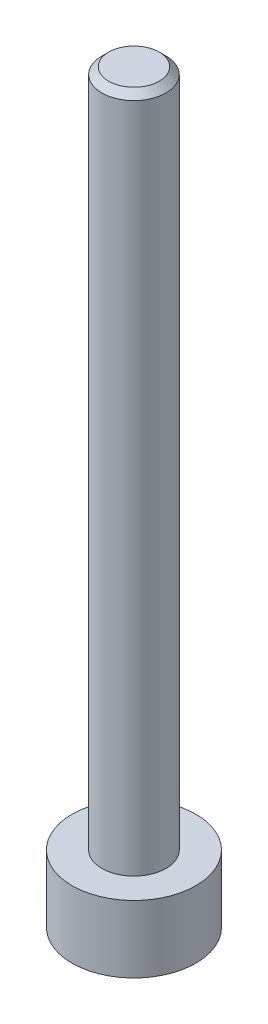
from build123d import *

# Parameters (mm, degrees)
SKETCH1_R           = 1.825
BOSS_EXTRUDE1_DEPTH = 1.98
SKETCH2_R           = 0.945
BOSS_EXTRUDE2_DEPTH = 20
CUT_EXTRUDE1_DEPTH  = 1
CHAMFER1_SIZE       = 0.2


with BuildPart() as part:
    # Sketch1 → Boss-Extrude1 (new body)
    with BuildSketch(Plane(origin=(0, 0, 0), x_dir=(1, 0, 0), z_dir=(0, 1, 0))):
        Circle(SKETCH1_R)
    extrude(amount=BOSS_EXTRUDE1_DEPTH)

    # Sketch2 → Boss-Extrude2 (add)
    with BuildSketch(Plane(origin=(0, 1.98, 0), x_dir=(1, 0, 0), z_dir=(0, 1, 0))):
        Circle(SKETCH2_R)
    extrude(amount=BOSS_EXTRUDE2_DEPTH)

    # Sketch3 → Cut-Extrude1 (cut)
    with BuildSketch(Plane.XZ):
        Polygon((0.458993464, -0.795), (0.917986928, 0), (0.458993464, 0.795), (-0.458993464, 0.795), (-0.917986928, 0), (-0.458993464, -0.795), align=None)
    extrude(amount=-CUT_EXTRUDE1_DEPTH, mode=Mode.SUBTRACT)

    # Chamfer1
    chamfer1_edges = [part.edges().sort_by_distance(p)[0] for p in [
        (-0.945, 21.98, 0),
    ]]
    chamfer(chamfer1_edges, length=CHAMFER1_SIZE)


solid = part.part
